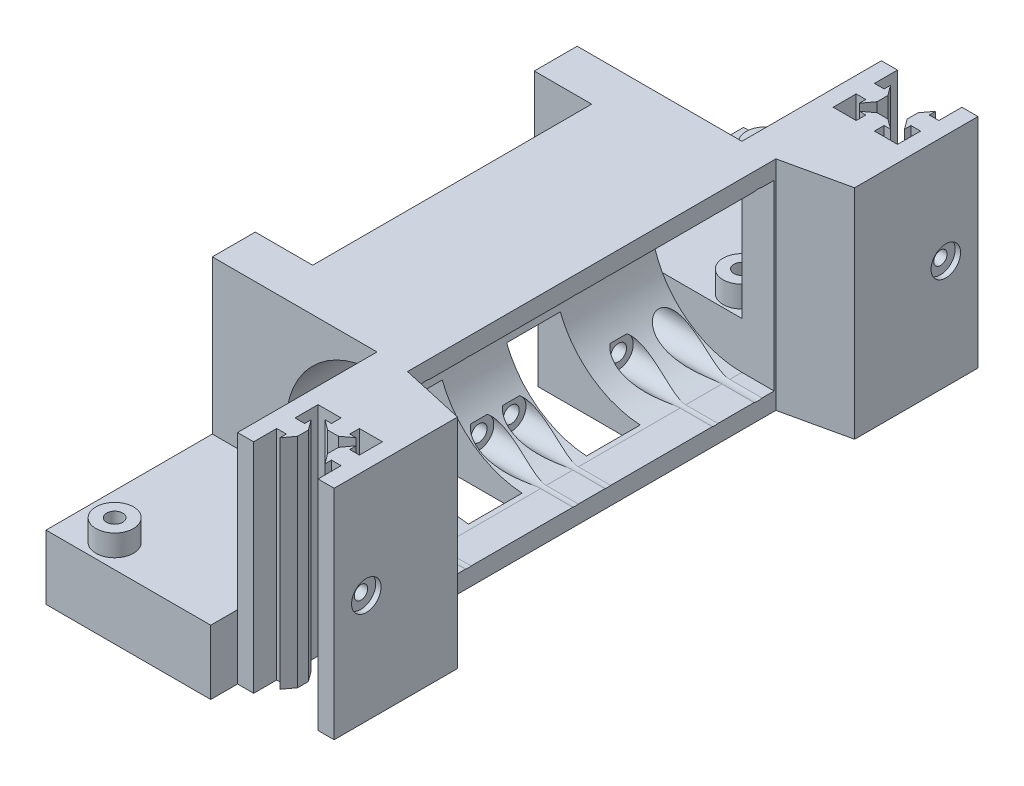
from build123d import *

# Parameters (mm, degrees)
BOSS_EXTRU_6_DEPTH           = 20.3
R_P_TITION_CIRCULAIRE3_COUNT = 3
R_P_TITION_CIRCULAIRE3_ANGLE = 180
ESQUISSE9_W                  = 18
ESQUISSE9_H                  = 3
ENL_V_MAT_EXTRU_1_DEPTH      = 41.6
ESQUISSE10_W                 = 6
ESQUISSE10_H                 = 40.6
BOSS_EXTRU_7_DEPTH           = 45
BOSS_EXTRU_8_DEPTH           = 40.6
ENL_V_MAT_EXTRU_3_REACH      = 20
ESQUISSE15_R                 = 1.25
ESQUISSE19_R                 = 2.75
ENL_V_MAT_EXTRU_5_DEPTH      = 1
ESQUISSE20_W                 = 31
ESQUISSE20_H                 = 12
BOSS_EXTRU_9_DEPTH           = 30.7
ESQUISSE21_R                 = 3.5
BOSS_EXTRU_10_DEPTH          = 4
ESQUISSE22_R                 = 1.5
ENL_V_MAT_EXTRU_6_DEPTH      = 17
ESQUISSE23_W                 = 24
ESQUISSE23_H                 = 40.6
BOSS_EXTRU_11_DEPTH          = 34
ENL_V_MAT_EXTRU_7_DEPTH      = 34
ESQUISSE25_W                 = 8
ESQUISSE25_H                 = 40.6
BOSS_EXTRU_16_DEPTH          = 10.7
ESQUISSE26_R                 = 1.5
ENL_V_MAT_EXTRU_8_DEPTH      = 39
ESQUISSE29_R                 = 2.75
ENL_V_MAT_EXTRU_13_DEPTH     = 31
R_P_TITION_LIN_AIRE1_COUNT   = 2
R_P_TITION_LIN_AIRE1_PITCH   = 20
SYM_TRIE2_COPY_1_SKETCH_R    = 1.5
SYM_TRIE2_COPY_1_DEPTH       = 39
SYM_TRIE2_COPY_2_SKETCH_R    = 2.75
SYM_TRIE2_COPY_2_DEPTH       = 31
ESQUISSE28_W                 = 26
ESQUISSE28_H                 = 20
BOSS_EXTRU_17_DEPTH          = 4
ESQUISSE30_R                 = 1.5
ENL_V_MAT_EXTRU_14_DEPTH     = 43
R_P_TITION_LIN_AIRE2_COUNT   = 2
R_P_TITION_LIN_AIRE2_PITCH   = 20
ESQUISSE31_R                 = 2.8
ENL_V_MAT_EXTRU_15_DEPTH     = 39
ENL_V_MAT_EXTRU_20_DEPTH     = 10
ESQUISSE35_R                 = 1.25
ENL_V_MAT_EXTRU_22_DEPTH     = 20
ESQUISSE36_R                 = 2.8
ENL_V_MAT_EXTRU_23_DEPTH     = 39
R_P_TITION_LIN_AIRE4_COUNT   = 3
R_P_TITION_LIN_AIRE4_PITCH   = 12


with BuildPart() as part:
    # Esquisse8 → Boss.-Extru.6 (new body, symmetric)
    with BuildSketch(Plane(origin=(0, 0, 0), x_dir=(1, 0, 0), z_dir=(0, 1, 0))):
        Polygon((-6, 1.7), (-4.2, 1.7), (-4.2, 2.9), (-2.8, 1), (-2.8, -1), (-4.2, -2.9), (-4.2, -1.7), (-6, -1.7), (-6, -9), (-9, -9), (-9, 9), (-6, 9), align=None)
    extrude(amount=BOSS_EXTRU_6_DEPTH, both=True)


with BuildPart() as r_p_tition_circulaire3_1:
    # Répétition circulaire3: pattern copy
    add(part.part.rotate(Axis((0, 0, 0), (0, -1, 0)), 1 * R_P_TITION_CIRCULAIRE3_ANGLE / (R_P_TITION_CIRCULAIRE3_COUNT - 1)))


with BuildPart() as r_p_tition_circulaire3_2:
    # Répétition circulaire3: pattern copy
    add(part.part.rotate(Axis((0, 0, 0), (0, -1, 0)), 2 * R_P_TITION_CIRCULAIRE3_ANGLE / (R_P_TITION_CIRCULAIRE3_COUNT - 1)))


with BuildPart() as enl_v_mat_extru_1_tool:
    # Esquisse9 → Enlèv. mat.-Extru.1 (new body, through all)
    with BuildSketch(Plane(origin=(0, 20.3, 0), x_dir=(1, 0, 0), z_dir=(0, 1, 0))):
        with Locations((0, -7.5)):
            Rectangle(ESQUISSE9_W, ESQUISSE9_H)
    extrude(amount=-ENL_V_MAT_EXTRU_1_DEPTH)


with BuildPart() as part_1:
    add(part.part)

    # Enlèv. mat.-Extru.1: cut by enl_v_mat_extru_1_tool
    add(enl_v_mat_extru_1_tool.part, mode=Mode.SUBTRACT)


    add(r_p_tition_circulaire3_1.part)  # Boss.-Extru.7 merges Répétition circulaire3_1
    # Esquisse10 → Boss.-Extru.7 (add)
    with BuildSketch(Plane(origin=(0, 0, -9), x_dir=(-1, 0, 0), z_dir=(0, 0, -1))):
        with Locations((6, 0)):
            Rectangle(ESQUISSE10_W, ESQUISSE10_H)
    extrude(amount=BOSS_EXTRU_7_DEPTH)



with BuildPart() as r_p_tition_circulaire3_2_1:
    add(r_p_tition_circulaire3_2.part)

    # Enlèv. mat.-Extru.1: cut by enl_v_mat_extru_1_tool
    add(enl_v_mat_extru_1_tool.part, mode=Mode.SUBTRACT)


with BuildPart() as part_2:
    add(part_1.part)

    add(r_p_tition_circulaire3_2_1.part)  # Boss.-Extru.8 merges Répétition circulaire3_2
    # Esquisse13 → Boss.-Extru.8 (add)
    with BuildSketch(Plane(origin=(0, -20.3, 0), x_dir=(-1, 0, 0), z_dir=(0, -1, 0))):
        Polygon((9, 21), (-9, 17), (-9, 9), (9, 9), align=None)
    extrude(amount=-BOSS_EXTRU_8_DEPTH)

    # Esquisse15 → Enlèv. mat.-Extru.3 (cut, up to next)
    with BuildSketch(Plane(origin=(9, 0, 0), x_dir=(0, 0, -1), z_dir=(1, 0, 0)), mode=Mode.PRIVATE) as enl_v_mat_extru_3_sk1:
        Circle(ESQUISSE15_R)
    enl_v_mat_extru_3_tool1 = extrude(enl_v_mat_extru_3_sk1.sketch, amount=-ENL_V_MAT_EXTRU_3_REACH, mode=Mode.PRIVATE) & part_2.part
    add(enl_v_mat_extru_3_tool1.solids().sort_by_distance((9, 0, 0))[0], mode=Mode.SUBTRACT)

    # Esquisse19 → Enlèv. mat.-Extru.5 (cut)
    with BuildSketch(Plane(origin=(9, 0, 0), x_dir=(0, 0, -1), z_dir=(1, 0, 0))):
        Circle(ESQUISSE19_R)
    extrude(amount=-ENL_V_MAT_EXTRU_5_DEPTH, mode=Mode.SUBTRACT)

    # Esquisse20 → Boss.-Extru.9 (add)
    with BuildSketch(Plane.ZY.offset(9)):
        with Locations((-4.5, -14.3)):
            Rectangle(ESQUISSE20_W, ESQUISSE20_H)
    extrude(amount=BOSS_EXTRU_9_DEPTH)

    # Esquisse21 → Boss.-Extru.10 (add)
    with BuildSketch(Plane(origin=(0, -8.3, 0), x_dir=(1, 0, 0), z_dir=(0, 1, 0))):
        with Locations((-31.3, -6.6)):
            Circle(ESQUISSE21_R)
        with Locations((-13, 16)):
            Circle(ESQUISSE21_R)
    extrude(amount=BOSS_EXTRU_10_DEPTH)

    # Esquisse22 → Enlèv. mat.-Extru.6 (cut, through all)
    with BuildSketch(Plane(origin=(0, -4.3, 0), x_dir=(1, 0, 0), z_dir=(0, 1, 0))):
        with Locations((-13, 16)):
            Circle(ESQUISSE22_R)
        with Locations((-31.3, -6.6)):
            Circle(ESQUISSE22_R)
    extrude(amount=-ENL_V_MAT_EXTRU_6_DEPTH, mode=Mode.SUBTRACT)

    # Esquisse23 → Boss.-Extru.11 (add)
    with BuildSketch(Plane(origin=(0, 0, -20), x_dir=(-1, 0, 0), z_dir=(0, 0, -1))):
        with Locations((17, 0)):
            Rectangle(ESQUISSE23_W, ESQUISSE23_H)
    extrude(amount=BOSS_EXTRU_11_DEPTH)

    # Esquisse24 → Enlèv. mat.-Extru.7 (cut)
    with BuildSketch(Plane.XY.offset(-54)):
        with BuildLine():
            Line((-9, 17), (11, 17))
            Line((11, 17), (11, -17))
            Line((11, -17), (-9, -17))
            ThreePointArc((-9, -17), (-26, 0), (-9, 17))
        make_face()
    extrude(amount=ENL_V_MAT_EXTRU_7_DEPTH, mode=Mode.SUBTRACT)

    # Esquisse25 → Boss.-Extru.16 (add)
    with BuildSketch(Plane.ZY.offset(29)):
        with Locations((-24, 0)):
            Rectangle(ESQUISSE25_W, ESQUISSE25_H)
    extrude(amount=BOSS_EXTRU_16_DEPTH)

    # Esquisse26 → Enlèv. mat.-Extru.8 (cut, through all)
    with BuildSketch(Plane.ZY.offset(29)):
        with Locations((-31, 14.3)):
            Circle(ESQUISSE26_R)
    enl_v_mat_extru_8 = extrude(amount=-ENL_V_MAT_EXTRU_8_DEPTH, mode=Mode.SUBTRACT)

    # Esquisse29 → Enlèv. mat.-Extru.13 (cut, through all)
    with BuildSketch(Plane.ZY.offset(21)):
        with Locations((-31, 14.3)):
            Circle(ESQUISSE29_R)
    enl_v_mat_extru_13 = extrude(amount=-ENL_V_MAT_EXTRU_13_DEPTH, mode=Mode.SUBTRACT)

    # Répétition linéaire1: Enlèv. mat.-Extru.8, Enlèv. mat.-Extru.13 ×2
    with Locations(*[(0, 0, -i * R_P_TITION_LIN_AIRE1_PITCH) for i in range(1, R_P_TITION_LIN_AIRE1_COUNT)]):
        add(enl_v_mat_extru_8, mode=Mode.SUBTRACT)
        add(enl_v_mat_extru_13, mode=Mode.SUBTRACT)

    # Symétrie2: Enlèv. mat.-Extru.8, Enlèv. mat.-Extru.13 across plane
    add(enl_v_mat_extru_8.mirror(Plane.ZX), mode=Mode.SUBTRACT)
    add(enl_v_mat_extru_13.mirror(Plane.ZX), mode=Mode.SUBTRACT)

    # Symétrie2 copy 1 sketch → Symétrie2 copy 1 (cut, through all)
    with BuildSketch(Plane(origin=(-29, 0, -20), x_dir=(0, 0, 1), z_dir=(-1, 0, 0))):
        with Locations((-31, -14.3)):
            Circle(SYM_TRIE2_COPY_1_SKETCH_R)
    extrude(amount=-SYM_TRIE2_COPY_1_DEPTH, mode=Mode.SUBTRACT)

    # Symétrie2 copy 2 sketch → Symétrie2 copy 2 (cut, through all)
    with BuildSketch(Plane(origin=(-21, 0, -20), x_dir=(0, 0, 1), z_dir=(-1, 0, 0))):
        with Locations((-31, -14.3)):
            Circle(SYM_TRIE2_COPY_2_SKETCH_R)
    extrude(amount=-SYM_TRIE2_COPY_2_DEPTH, mode=Mode.SUBTRACT)

    # Esquisse28 → Boss.-Extru.17 (add)
    with BuildSketch(Plane.ZY.offset(29)):
        with Locations((-41, 0)):
            Rectangle(ESQUISSE28_W, ESQUISSE28_H)
    extrude(amount=BOSS_EXTRU_17_DEPTH)

    # Esquisse30 → Enlèv. mat.-Extru.14 (cut, through all)
    with BuildSketch(Plane.ZY.offset(33)):
        with Locations((-31, 0)):
            Circle(ESQUISSE30_R)
    enl_v_mat_extru_14 = extrude(amount=-ENL_V_MAT_EXTRU_14_DEPTH, mode=Mode.SUBTRACT)

    # Répétition linéaire2: Enlèv. mat.-Extru.14 ×2
    with Locations(*[(0, 0, -i * R_P_TITION_LIN_AIRE2_PITCH) for i in range(1, R_P_TITION_LIN_AIRE2_COUNT)]):
        add(enl_v_mat_extru_14, mode=Mode.SUBTRACT)

    # Esquisse31 → Enlèv. mat.-Extru.15 (cut, through all)
    with BuildSketch(Plane.ZY.offset(29)):
        with Locations((-31, 0)):
            Circle(ESQUISSE31_R)
    extrude(amount=-ENL_V_MAT_EXTRU_15_DEPTH, mode=Mode.SUBTRACT)

    # Esquisse34 → Enlèv. mat.-Extru.20 (cut)
    with BuildSketch(Plane.XY.offset(-48)):
        Polygon((-26.29496732, -5.314745962), (-36.29496732, -22.635254038), (-13.235010893, -22.635254038), (-9, -15.3), align=None)
    extrude(amount=ENL_V_MAT_EXTRU_20_DEPTH, mode=Mode.SUBTRACT)

    # Esquisse35 → Enlèv. mat.-Extru.22 (cut)
    with BuildSketch(Plane.ZY.offset(39.7)):
        with Locations((-23, -14.3)):
            Circle(ESQUISSE35_R)
    enl_v_mat_extru_22 = extrude(amount=-ENL_V_MAT_EXTRU_22_DEPTH, mode=Mode.SUBTRACT)

    # Esquisse36 → Enlèv. mat.-Extru.23 (cut, through all)
    with BuildSketch(Plane.ZY.offset(29)):
        with Locations((-23, -14.3)):
            Circle(ESQUISSE36_R)
    enl_v_mat_extru_23 = extrude(amount=-ENL_V_MAT_EXTRU_23_DEPTH, mode=Mode.SUBTRACT)

    # Répétition linéaire4: Enlèv. mat.-Extru.22 ×3
    with Locations(*[(0, 0, i * R_P_TITION_LIN_AIRE4_PITCH) for i in range(1, R_P_TITION_LIN_AIRE4_COUNT)]):
        add(enl_v_mat_extru_22, mode=Mode.SUBTRACT)

    # Symétrie9: Enlèv. mat.-Extru.22, Enlèv. mat.-Extru.23 across plane
    add(enl_v_mat_extru_22.mirror(Plane.ZX), mode=Mode.SUBTRACT)
    add(enl_v_mat_extru_23.mirror(Plane.ZX), mode=Mode.SUBTRACT)

    # Symétrie10: part across plane


with BuildPart() as part_3:
    add(part_2.part)
    add(part_2.part.mirror(Plane.XY.offset(-54)))


solid = part_3.part
